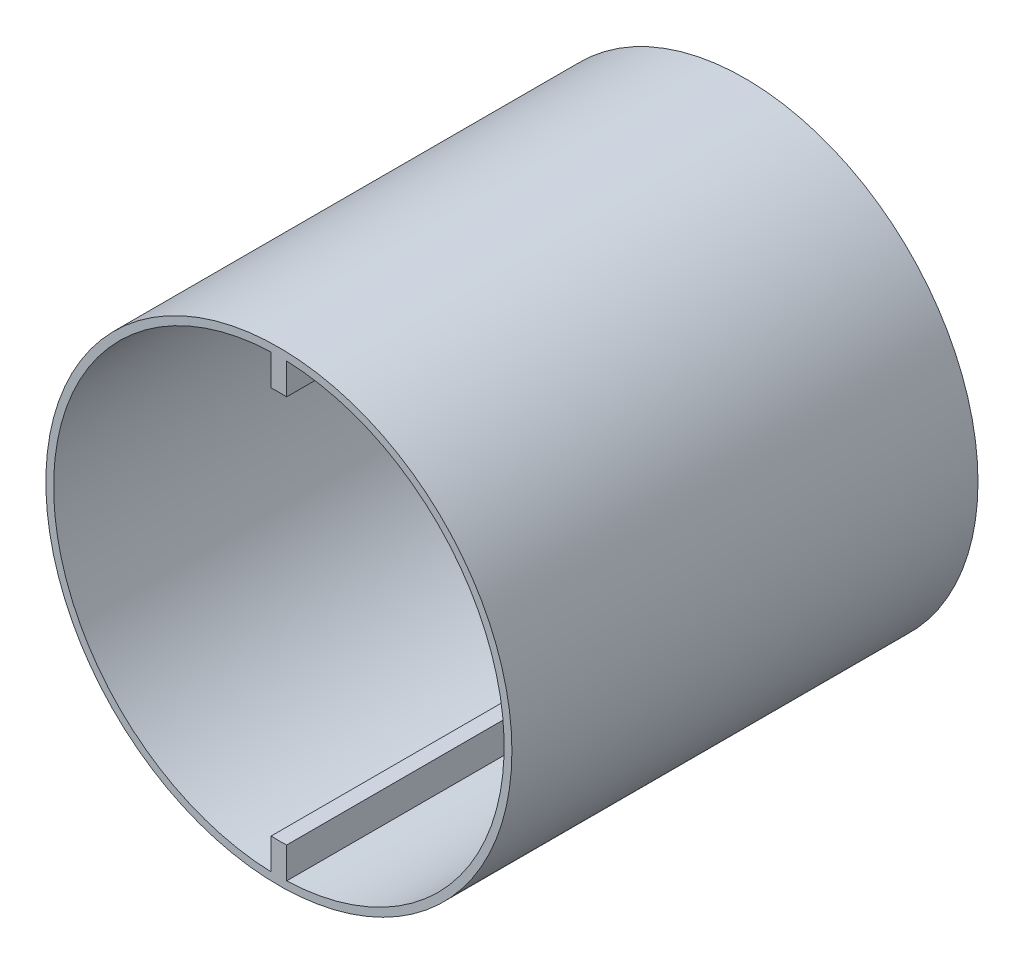
from build123d import *

# Parameters (mm, degrees)
BOSS_EXTRU_1_DEPTH      = 60
ESQUISSE2_R             = 30
ESQUISSE2_R_2           = 29
BOSS_EXTRU_2_DEPTH      = 60
ESQUISSE3_R             = 25
ENL_V_MAT_EXTRU_1_DEPTH = 27
ESQUISSE6_R             = 2.225
ENL_V_MAT_EXTRU_3_DEPTH = 2
ESQUISSE11_R            = 25
ESQUISSE11_R_2          = 3.5
ENL_V_MAT_EXTRU_8_DEPTH = 31


with BuildPart() as part:
    # Esquisse1 → Boss.-Extru.1 (new body)
    with BuildSketch(Plane.XY):
        with BuildLine():
            Line((1, -15.006468588), (1, -3.354101966))
            ThreePointArc((1, -3.354101966), (3.5, 0), (1, 3.354101966))
            Line((1, 3.354101966), (1, 29.5))
            Line((1, 29.5), (-1, 29.5))
            Line((-1, 29.5), (-1, 3.354101966))
            ThreePointArc((-1, 3.354101966), (-3.5, 0), (-1, -3.354101966))
            Line((-1, -3.354101966), (-1, -29.5))
            Line((-1, -29.5), (1, -29.5))
            Line((1, -29.5), (1, -15.006468588))
        make_face()
    extrude(amount=BOSS_EXTRU_1_DEPTH)

    # Esquisse2 → Boss.-Extru.2 (add)
    with BuildSketch(Plane.XY.offset(60)):
        Circle(ESQUISSE2_R)
        Circle(ESQUISSE2_R_2, mode=Mode.SUBTRACT)
    extrude(amount=-BOSS_EXTRU_2_DEPTH)

    # Esquisse3 → Enlèv. mat.-Extru.1 (cut)
    with BuildSketch(Plane.XY.offset(60)):
        Circle(ESQUISSE3_R)
    extrude(amount=-ENL_V_MAT_EXTRU_1_DEPTH, mode=Mode.SUBTRACT)

    # Esquisse6 → Enlèv. mat.-Extru.3 (cut)
    with BuildSketch(Plane.XY.offset(33)):
        Circle(ESQUISSE6_R)
    extrude(amount=-ENL_V_MAT_EXTRU_3_DEPTH, mode=Mode.SUBTRACT)

    # Esquisse11 → Enlèv. mat.-Extru.8 (cut)
    with BuildSketch(Plane.XY.offset(60)):
        Circle(ESQUISSE11_R)
        Circle(ESQUISSE11_R_2, mode=Mode.SUBTRACT)
    extrude(amount=-ENL_V_MAT_EXTRU_8_DEPTH, mode=Mode.SUBTRACT)


solid = part.part
